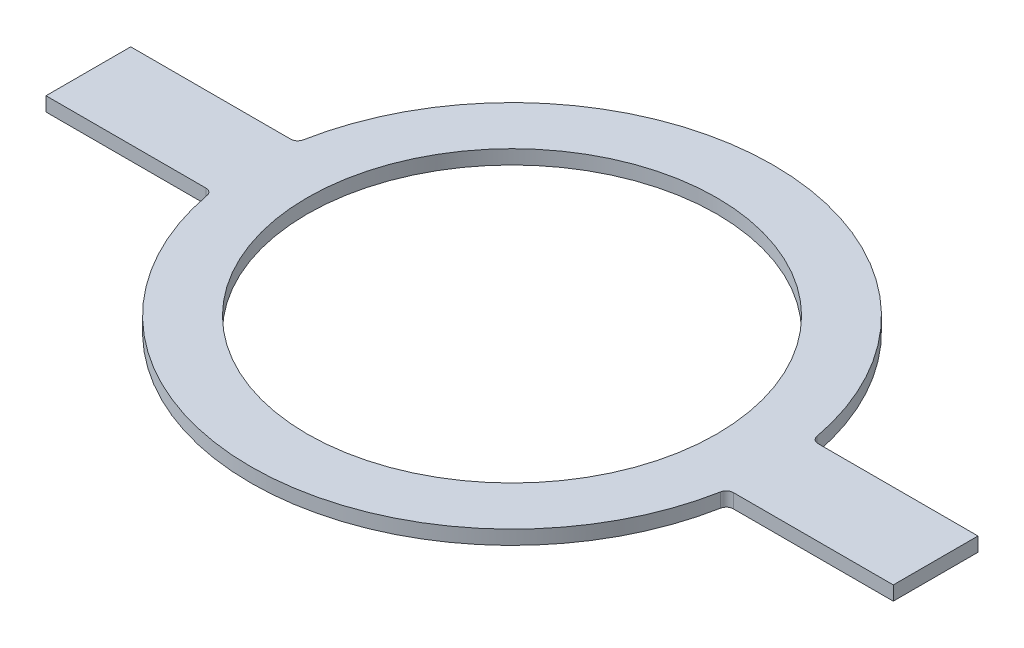
from build123d import *

# Parameters (mm, degrees)
SKETCH1_R           = 92.075
BOSS_EXTRUDE1_DEPTH = 6.35
FILLET1_R           = 3.175


with BuildPart() as part:
    # Sketch1 → Boss-Extrude1 (new body)
    with BuildSketch(Plane(origin=(0, 0, 0), x_dir=(1, 0, 0), z_dir=(0, 1, 0))):
        with BuildLine():
            Line((115.920115273, 19.05), (190.5, 19.05))
            Line((190.5, 19.05), (190.5, -19.05))
            Line((190.5, -19.05), (115.920115273, -19.05))
            ThreePointArc((115.920115273, -19.05), (0, -117.475), (-115.920115273, -19.05))
            Line((-115.920115273, -19.05), (-190.5, -19.05))
            Line((-190.5, -19.05), (-190.5, 19.05))
            Line((-190.5, 19.05), (-115.920115273, 19.05))
            ThreePointArc((-115.920115273, 19.05), (0, 117.475), (115.920115273, 19.05))
        make_face()
        with Locations(Location((0, 0, 0), (0, 0, 270))):  # turned: the seam where the file's is
            Circle(SKETCH1_R, mode=Mode.SUBTRACT)
    extrude(amount=BOSS_EXTRUDE1_DEPTH)

    # Fillet1
    fillet1_edges = [part.edges().sort_by_distance(p)[0] for p in [
        (115.920115273, 3.175, 19.05),
        (-115.920115273, 3.175, 19.05),
        (-115.920115273, 3.175, -19.05),
        (115.920115273, 3.175, -19.05),
    ]]
    fillet(fillet1_edges, radius=FILLET1_R)


solid = part.part
